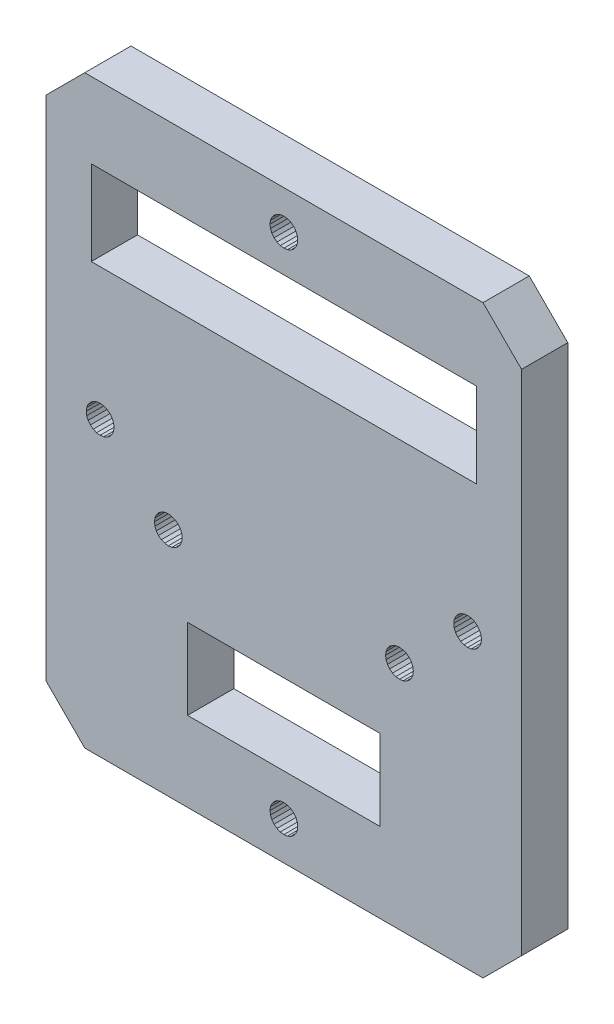
from build123d import *

# Parameters (mm, degrees)
SKETCH1_W           = 24.999989911
SKETCH1_H           = 10.457138345
SKETCH1_W_2         = 49.999979697
SKETCH1_H_2         = 10.999995004
BOSS_EXTRUDE1_DEPTH = 6


with BuildPart() as part:
    # Sketch1 → Boss-Extrude1 (new body)
    with BuildSketch(Plane.XY):
        Polygon((-65.562023318, 106.501824812), (-13.869587203, 106.501824812), (-8.869589203, 111.501822737), (-8.86958929, 177.416081581), (-13.869587182, 182.416079474), (-65.562023318, 182.416079474), (-70.562021318, 177.416081474), (-70.562021318, 111.501822812), align=None)
        with Locations((-39.715805178, 122.080389652)):
            Rectangle(SKETCH1_W, SKETCH1_H, mode=Mode.SUBTRACT)
        with Locations((-39.715804889, 167.108942347)):
            Rectangle(SKETCH1_W_2, SKETCH1_H_2, mode=Mode.SUBTRACT)
        Polygon((-64.027895413, 142.720286351), (-63.562021318, 142.658952863), (-63.096147223, 142.720286351), (-62.662021678, 142.90010704), (-62.289229621, 143.186160446), (-62.003176215, 143.558952503), (-61.823355526, 143.993078048), (-61.762022038, 144.458952143), (-61.823355526, 144.924826238), (-62.003176215, 145.358951783), (-62.289229621, 145.73174384), (-62.662021678, 146.017797246), (-63.096147223, 146.197617935), (-63.562021318, 146.258951423), (-64.027895413, 146.197617935), (-64.462020958, 146.017797246), (-64.834813015, 145.73174384), (-65.120866421, 145.358951783), (-65.30068711, 144.924826238), (-65.362020598, 144.458952143), (-65.30068711, 143.993078048), (-65.120866421, 143.558952503), (-64.834813015, 143.186160446), (-64.462020958, 142.90010704), align=None, mode=Mode.SUBTRACT)
        Polygon((-15.869589241, 146.258951423), (-16.335463335, 146.197617935), (-16.769588881, 146.017797246), (-17.142380938, 145.73174384), (-17.428434344, 145.358951783), (-17.608255032, 144.924826238), (-17.669588521, 144.458952143), (-17.608255032, 143.993078048), (-17.428434344, 143.558952503), (-17.142380938, 143.186160446), (-16.769588881, 142.90010704), (-16.335463335, 142.720286351), (-15.869589241, 142.658952863), (-15.403715146, 142.720286351), (-14.969589601, 142.90010704), (-14.596797544, 143.186160446), (-14.310744137, 143.558952503), (-14.130923449, 143.993078048), (-14.069589961, 144.458952143), (-14.130923449, 144.924826238), (-14.310744137, 145.358951783), (-14.596797544, 145.73174384), (-14.969589601, 146.017797246), (-15.403715146, 146.197617935), align=None, mode=Mode.SUBTRACT)
        Polygon((-37.977139407, 111.967698907), (-38.156960096, 112.401824452), (-38.443013502, 112.774616509), (-38.815805559, 113.060669915), (-39.249931104, 113.240490604), (-39.715805199, 113.301824092), (-40.181679294, 113.240490604), (-40.615804839, 113.060669915), (-40.988596896, 112.774616509), (-41.274650303, 112.401824452), (-41.454470991, 111.967698907), (-41.515804479, 111.501824812), (-41.454470991, 111.035950717), (-41.274650303, 110.601825172), (-40.988596896, 110.229033115), (-40.615804839, 109.942979709), (-40.181679294, 109.76315902), (-39.715805199, 109.701825532), (-39.249931104, 109.76315902), (-38.815805559, 109.942979709), (-38.443013502, 110.229033115), (-38.156960096, 110.601825172), (-37.977139407, 111.035950717), (-37.915805919, 111.501824812), align=None, mode=Mode.SUBTRACT)
        Polygon((-37.977139407, 176.950205359), (-37.915805919, 177.416079454), (-37.977139407, 177.881953549), (-38.156960096, 178.316079094), (-38.443013502, 178.688871151), (-38.815805559, 178.974924557), (-39.249931104, 179.154745246), (-39.715805199, 179.216078734), (-40.181679294, 179.154745246), (-40.615804839, 178.974924557), (-40.988596896, 178.688871151), (-41.274650303, 178.316079094), (-41.454470991, 177.881953549), (-41.515804479, 177.416079454), (-41.454470991, 176.950205359), (-41.274650303, 176.516079814), (-40.988596896, 176.143287757), (-40.615804839, 175.857234351), (-40.181679294, 175.677413662), (-39.715805199, 175.616080174), (-39.249931104, 175.677413662), (-38.815805559, 175.857234351), (-38.443013502, 176.143287757), (-38.156960096, 176.516079814), align=None, mode=Mode.SUBTRACT)
        Polygon((-55.181679294, 134.720286351), (-54.715805199, 134.658952863), (-54.249931104, 134.720286351), (-53.815805559, 134.90010704), (-53.443013502, 135.186160446), (-53.156960096, 135.558952503), (-52.977139407, 135.993078048), (-52.915805919, 136.458952143), (-52.977139407, 136.924826238), (-53.156960096, 137.358951783), (-53.443013502, 137.73174384), (-53.815805559, 138.017797246), (-54.249931104, 138.197617935), (-54.715805199, 138.258951423), (-55.181679294, 138.197617935), (-55.615804839, 138.017797246), (-55.988596896, 137.73174384), (-56.274650303, 137.358951783), (-56.454470991, 136.924826238), (-56.515804479, 136.458952143), (-56.454470991, 135.993078048), (-56.274650303, 135.558952503), (-55.988596896, 135.186160446), (-55.615804839, 134.90010704), align=None, mode=Mode.SUBTRACT)
        Polygon((-23.156960096, 137.358951783), (-23.443013502, 137.73174384), (-23.815805559, 138.017797246), (-24.249931104, 138.197617935), (-24.715805199, 138.258951423), (-25.181679294, 138.197617935), (-25.615804839, 138.017797246), (-25.988596896, 137.73174384), (-26.274650303, 137.358951783), (-26.454470991, 136.924826238), (-26.515804479, 136.458952143), (-26.454470991, 135.993078048), (-26.274650303, 135.558952503), (-25.988596896, 135.186160446), (-25.615804839, 134.90010704), (-25.181679294, 134.720286351), (-24.715805199, 134.658952863), (-24.249931104, 134.720286351), (-23.815805559, 134.90010704), (-23.443013502, 135.186160446), (-23.156960096, 135.558952503), (-22.977139407, 135.993078048), (-22.915805919, 136.458952143), (-22.977139407, 136.924826238), align=None, mode=Mode.SUBTRACT)
    extrude(amount=BOSS_EXTRUDE1_DEPTH)


solid = part.part
